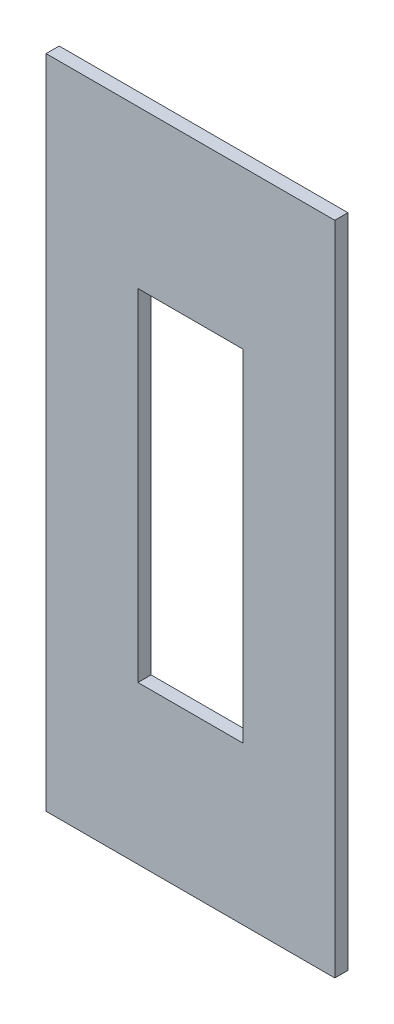
from build123d import *

# Parameters (mm, degrees)
SKETCH_1_W      = 11
SKETCH_1_H      = 25
SKETCH_1_W_2    = 4
SKETCH_1_H_2    = 13
EXTRUDE_1_DEPTH = 0.5


with BuildPart() as part:
    # Эскиз1 → Вытянуть1 (new body)
    with BuildSketch(Plane.XY):
        Rectangle(SKETCH_1_W, SKETCH_1_H)
        Rectangle(SKETCH_1_W_2, SKETCH_1_H_2, mode=Mode.SUBTRACT)
    extrude(amount=EXTRUDE_1_DEPTH)


solid = part.part
